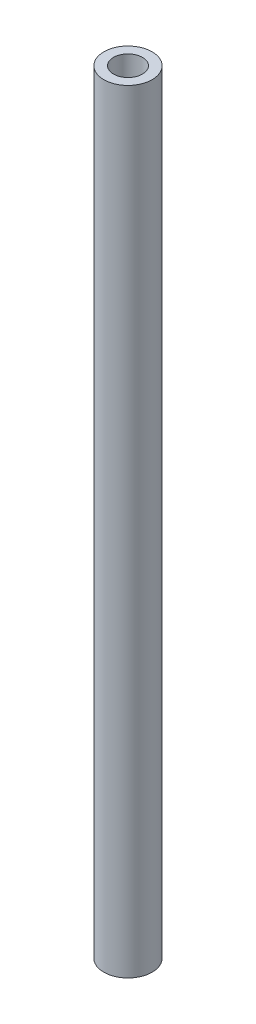
from build123d import *

# Parameters (mm, degrees)
SKETCH1_R           = 2.5
SKETCH1_R_2         = 1.5
BOSS_EXTRUDE1_DEPTH = 80


with BuildPart() as part:
    # Sketch1 → Boss-Extrude1 (new body)
    with BuildSketch(Plane(origin=(0, 0, 0), x_dir=(1, 0, 0), z_dir=(0, 1, 0))):
        Circle(SKETCH1_R)
        Circle(SKETCH1_R_2, mode=Mode.SUBTRACT)
    extrude(amount=BOSS_EXTRUDE1_DEPTH)


solid = part.part
